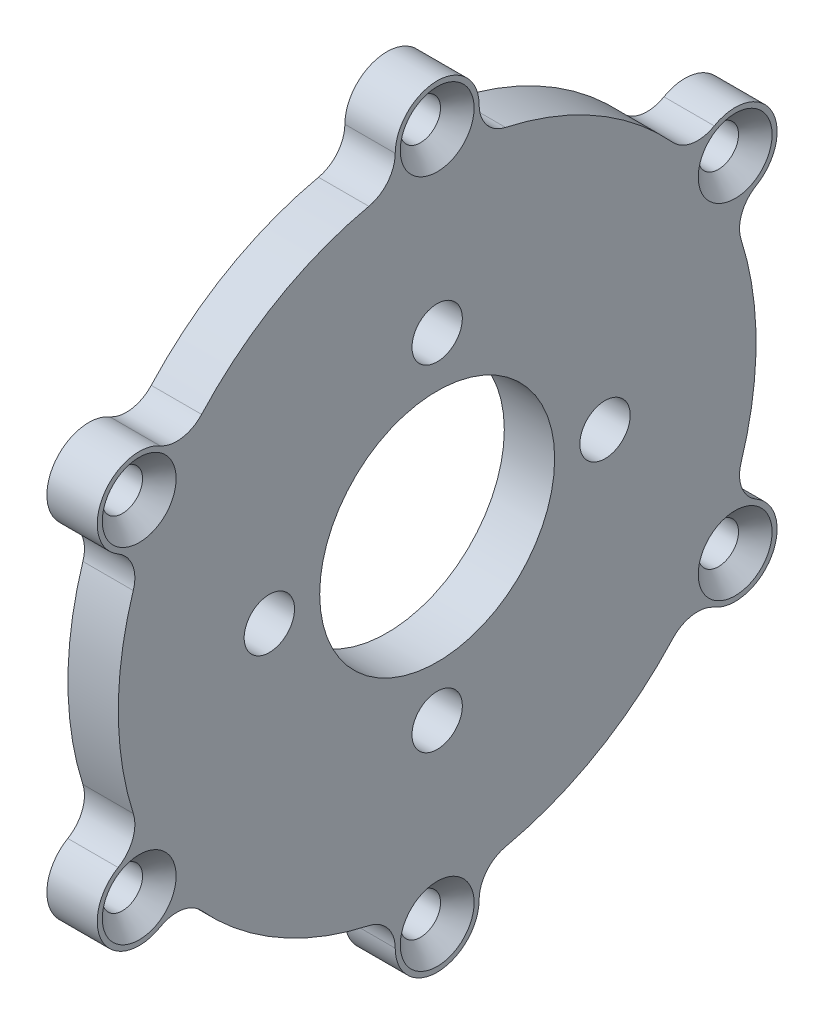
from build123d import *

# Parameters (mm, degrees)
SKETCH1_W                                           = 3
SKETCH1_H                                           = 12
CIRPATTERN1_COUNT                                   = 4
SKETCH7_R                                           = 2.5
BOSS_EXTRUDE1_DEPTH                                 = 3
SKETCH8_W                                           = 5
SKETCH8_H                                           = 4.78706329
BOSS_EXTRUDE2_DEPTH                                 = 3
CSK_FOR_M2_COUNTERSUNK_FLAT_HEAD_SCREW1_D           = 2.4
CSK_FOR_M2_COUNTERSUNK_FLAT_HEAD_SCREW1_CSINK_D     = 4.4
CSK_FOR_M2_COUNTERSUNK_FLAT_HEAD_SCREW1_CSINK_ANGLE = 90
CIRPATTERN2_COUNT                                   = 6
FILLET1_R                                           = 2
SKETCH12_R                                          = 17
SKETCH12_R_2                                        = 12.5
CUT_EXTRUDE1_DEPTH                                  = 1.5
FILLET2_R                                           = 0.5


with BuildPart() as part:
    # Sketch1 → Revolve1 (revolve)
    with BuildSketch(Plane.XY):
        with Locations((0, 13)):
            Rectangle(SKETCH1_W, SKETCH1_H)
    revolve(axis=Axis((0, 0, 0), (-1, 0, 0)))

    # Sketch4 → Ø3.0 (3) Diameter Hole2 (revolve, cut)
    with BuildSketch(Plane(origin=(1.5, 10, 0), x_dir=(0, 0, -1), z_dir=(0, 1, 0))):
        Polygon((0, 0), (0, 6.901290929), (1.5, 6), (1.5, 0), align=None)
    f_3_0_3_diameter_hole2 = revolve(axis=Axis((7.85, 10, 0), (-1, 0, 0)), mode=Mode.SUBTRACT)

    # CirPattern1: Ø3.0 (3) Diameter Hole2 ×4 about axis
    cirpattern1_axis = Axis((0, 0, 0), (1, 0, 0))
    for i in range(1, CIRPATTERN1_COUNT):
        add(f_3_0_3_diameter_hole2.rotate(cirpattern1_axis, i * 360 / CIRPATTERN1_COUNT), mode=Mode.SUBTRACT)

    # Sketch7 → Boss-Extrude1 (add)
    with BuildSketch(Plane(origin=(1.5, 0, 0), x_dir=(0, 0, -1), z_dir=(1, 0, 0))):
        with Locations((0, 20.5)):
            Circle(SKETCH7_R)
    boss_extrude1 = extrude(amount=-BOSS_EXTRUDE1_DEPTH)

    # Sketch8 → Boss-Extrude2 (add)
    with BuildSketch(Plane(origin=(1.5, 0, 0), x_dir=(0, 0, -1), z_dir=(1, 0, 0))):
        with Locations((0, 18.106468355)):
            Rectangle(SKETCH8_W, SKETCH8_H)
    boss_extrude2 = extrude(amount=-BOSS_EXTRUDE2_DEPTH)

    # CSK for M2 Countersunk Flat Head Screw1 (through all)
    with Locations(Plane(origin=(1.5, 0, 0), x_dir=(0, 0, -1), z_dir=(1, 0, 0))):
        with Locations((0, 20.5)):
            csk_for_m2_countersunk_flat_head_screw1 = CounterSinkHole(CSK_FOR_M2_COUNTERSUNK_FLAT_HEAD_SCREW1_D / 2, CSK_FOR_M2_COUNTERSUNK_FLAT_HEAD_SCREW1_CSINK_D / 2, counter_sink_angle=CSK_FOR_M2_COUNTERSUNK_FLAT_HEAD_SCREW1_CSINK_ANGLE)

    # CirPattern2: Boss-Extrude1, Boss-Extrude2, CSK for M2 Countersunk Flat Head Screw1 ×6 about axis
    cirpattern2_axis = Axis((0, 0, 0), (1, 0, 0))
    for i in range(1, CIRPATTERN2_COUNT):
        add(boss_extrude1.rotate(cirpattern2_axis, i * 360 / CIRPATTERN2_COUNT))
        add(boss_extrude2.rotate(cirpattern2_axis, i * 360 / CIRPATTERN2_COUNT))
        add(csk_for_m2_countersunk_flat_head_screw1.rotate(cirpattern2_axis, i * 360 / CIRPATTERN2_COUNT), mode=Mode.SUBTRACT)

    # Fillet1
    fillet1_edges = [part.edges().sort_by_distance(p)[0] for p in [
        (0, 11.58246761, -15.061422378),
        (0, 7.252340591, -17.561422378),
        (0, -7.252340591, -17.561422378),
        (0, -11.58246761, -15.061422378),
        (0, -18.834808202, -2.5),
        (0, -18.834808202, 2.5),
        (0, -11.58246761, 15.061422378),
        (0, -7.252340591, 17.561422378),
        (0, 7.252340591, 17.561422378),
        (0, 11.58246761, 15.061422378),
        (0, 18.834808202, -2.5),
        (0, 18.834808202, 2.5),
    ]]
    fillet(fillet1_edges, radius=FILLET1_R)

    # Sketch12 → Cut-Extrude1 (cut)
    with BuildSketch(Plane.ZY.offset(1.5)):
        Circle(SKETCH12_R)
        Circle(SKETCH12_R_2, mode=Mode.SUBTRACT)
    extrude(amount=-CUT_EXTRUDE1_DEPTH, mode=Mode.SUBTRACT)

    # Fillet2
    fillet2_edges = [part.edges().sort_by_distance(p)[0] for p in [
        (0, 0, -17),
        (0, 0, -12.5),
    ]]
    fillet(fillet2_edges, radius=FILLET2_R)


solid = part.part
